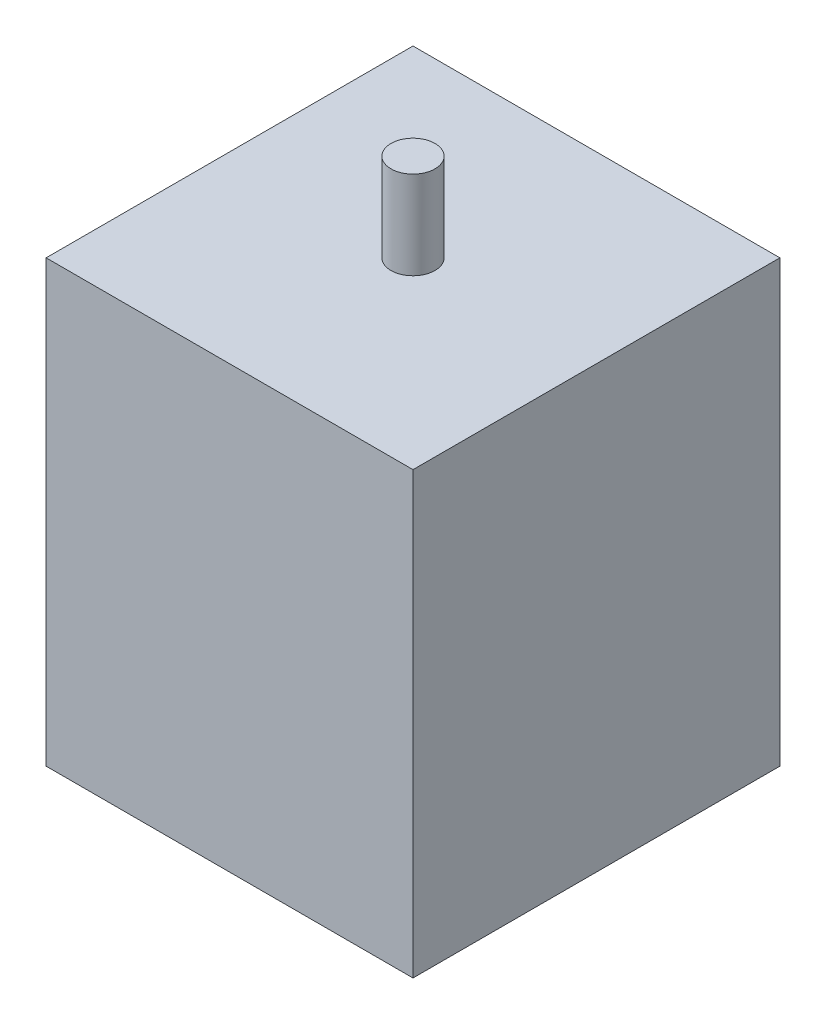
from build123d import *

# Parameters (mm, degrees)
SKETCH1_W           = 50
SKETCH1_H           = 50
BOSS_EXTRUDE1_DEPTH = 60
SKETCH2_R           = 3
BOSS_EXTRUDE2_DEPTH = 12


with BuildPart() as part:
    # Sketch1 → Boss-Extrude1 (new body)
    with BuildSketch(Plane(origin=(0, 0, 0), x_dir=(1, 0, 0), z_dir=(0, 1, 0))):
        Rectangle(SKETCH1_W, SKETCH1_H)
    extrude(amount=BOSS_EXTRUDE1_DEPTH)

    # Sketch2 → Boss-Extrude2 (add)
    with BuildSketch(Plane(origin=(0, 60, 0), x_dir=(1, 0, 0), z_dir=(0, 1, 0))):
        Circle(SKETCH2_R)
    extrude(amount=BOSS_EXTRUDE2_DEPTH)


solid = part.part
